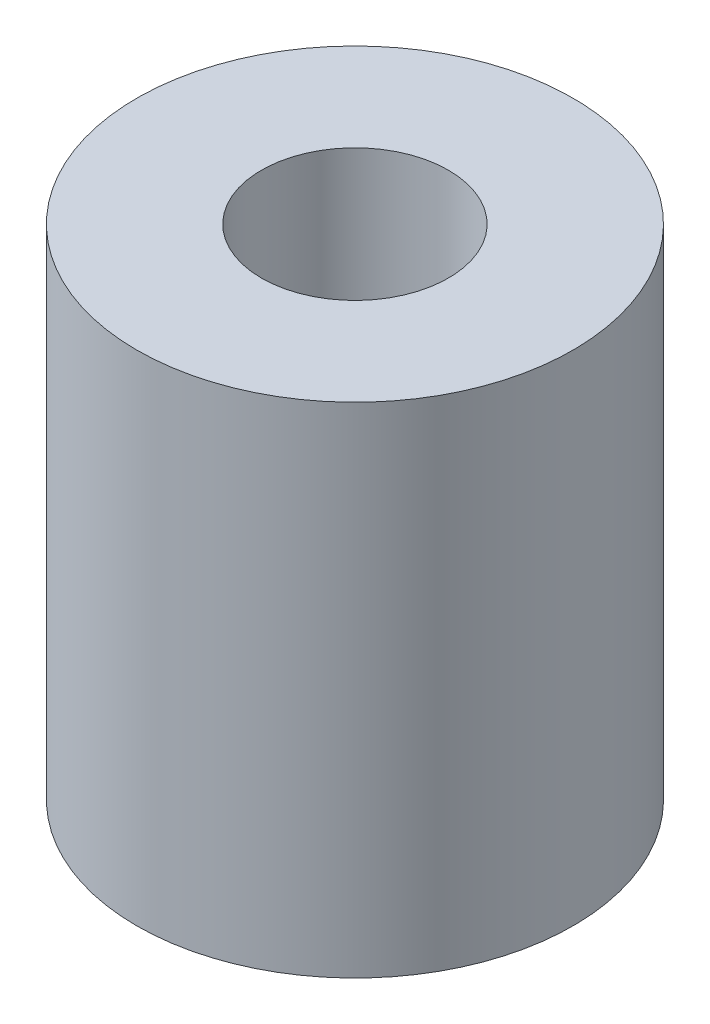
from build123d import *

# Parameters (mm, degrees)
SKETCH_1_R      = 3.5
SKETCH_1_R_2    = 1.5
EXTRUDE_1_DEPTH = 8


with BuildPart() as part:
    # 草图1 → 凸台-拉伸1 (new body)
    with BuildSketch(Plane(origin=(0, 0, 0), x_dir=(1, 0, 0), z_dir=(0, 1, 0))):
        Circle(SKETCH_1_R)
        Circle(SKETCH_1_R_2, mode=Mode.SUBTRACT)
    extrude(amount=EXTRUDE_1_DEPTH)


solid = part.part
